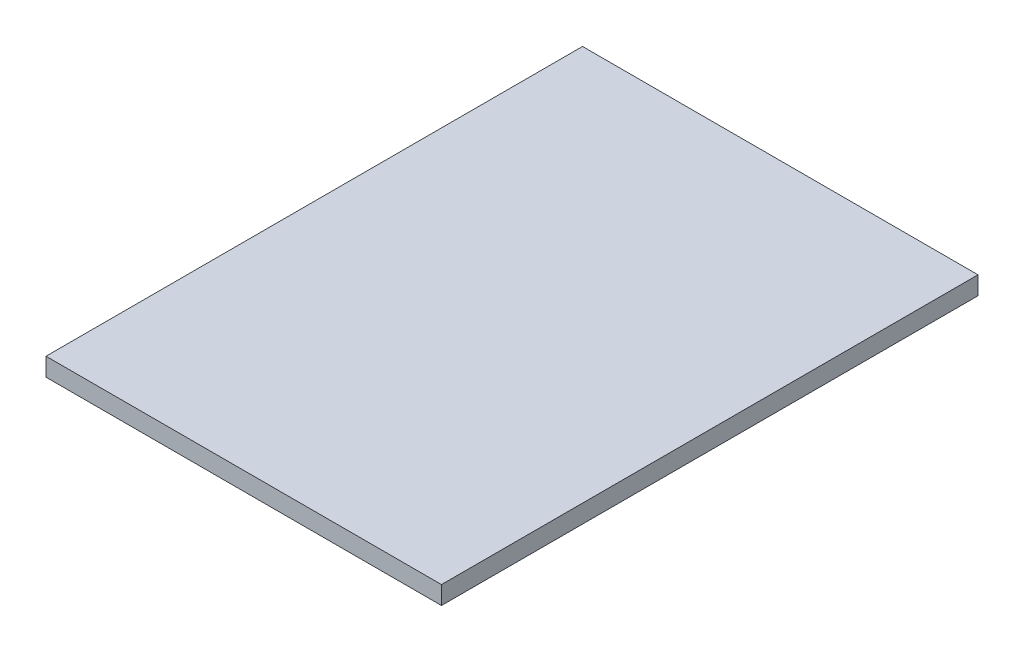
from build123d import *

# Parameters (mm, degrees)
SKETCH1_W           = 65.26818369
SKETCH1_H           = 88.544137004
BOSS_EXTRUDE1_DEPTH = 3


with BuildPart() as part:
    # Sketch1 → Boss-Extrude1 (new body)
    with BuildSketch(Plane(origin=(0, 0, 0), x_dir=(1, 0, 0), z_dir=(0, 1, 0))):
        Rectangle(SKETCH1_W, SKETCH1_H)
    extrude(amount=BOSS_EXTRUDE1_DEPTH)


solid = part.part
